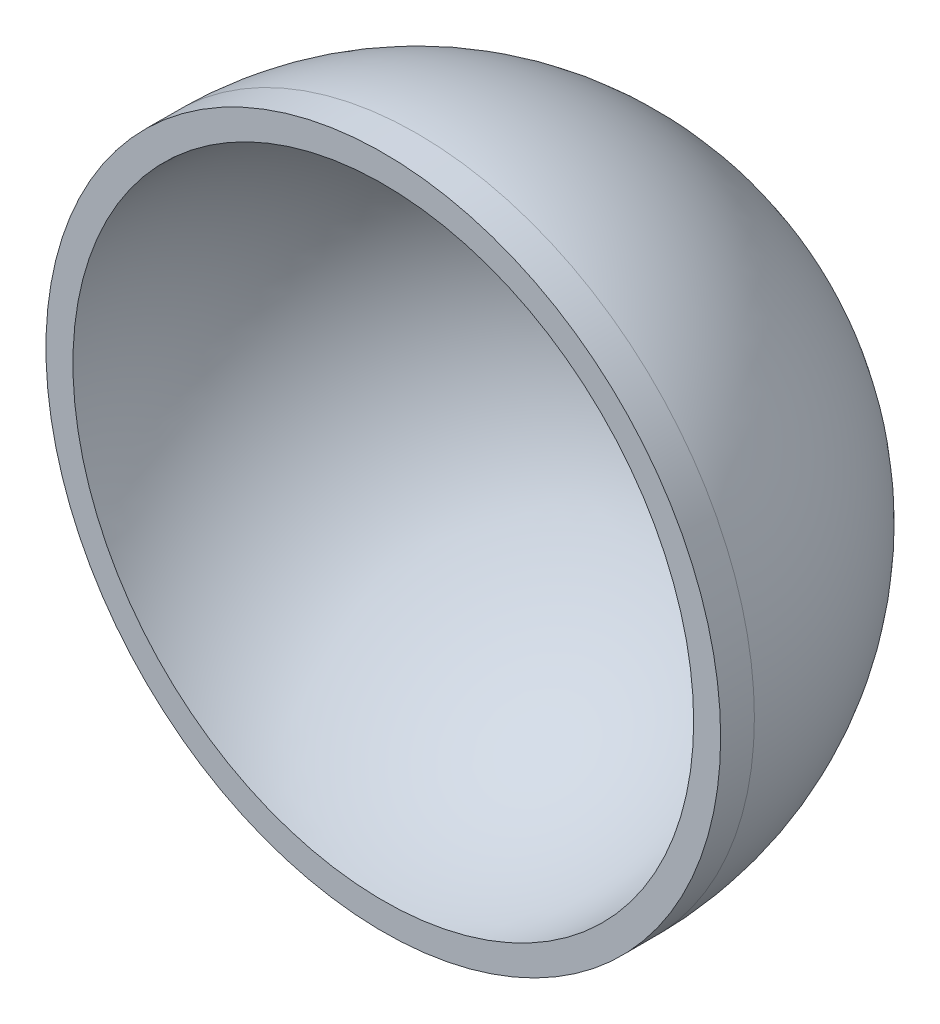
from build123d import *

# Parameters (mm, degrees)
SKETCH1_R           = 50
BOSS_EXTRUDE1_DEPTH = 5
REVOLVE1_ANGLE      = 180


with BuildPart() as part:
    # Sketch1 → Boss-Extrude1 (new body)
    with BuildSketch(Plane.XY):
        Circle(SKETCH1_R)
    extrude(amount=-BOSS_EXTRUDE1_DEPTH)

    # Sketch2 → Revolve1 (revolve)
    with BuildSketch(Plane(origin=(0, 0, -5), x_dir=(-1, 0, 0), z_dir=(0, 0, -1))):
        with BuildLine():
            Line((0, -50), (0, 50))
            ThreePointArc((0, 50), (50, 0), (0, -50))
        make_face()
    revolve(axis=Axis((0, -50, -5), (0, -1, 0)), revolution_arc=REVOLVE1_ANGLE)

    # Sketch4 → Cut-Revolve1 (revolve, cut)
    with BuildSketch(Plane.XY):
        with BuildLine():
            Line((0, -46), (0, 46))
            ThreePointArc((0, 46), (46, 0), (0, -46))
        make_face()
    revolve(axis=Axis((0, -46, 0), (0, 1, 0)), mode=Mode.SUBTRACT)


solid = part.part
